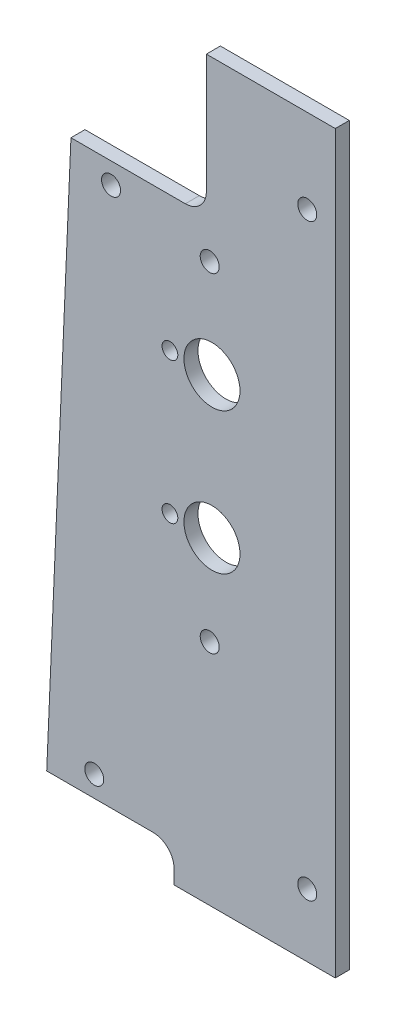
from build123d import *

# Parameters (mm, degrees)
BOSS_EXTRUDE1_DEPTH             = 3.175
F_9_64_0_14063_DIAMETER_HOLE1_D = 3.572002
F_1_2_0_5_DIAMETER_HOLE1_D      = 12.7
F_6_CLEARANCE_HOLE1_D           = 4.3053
F_6_CLEARANCE_HOLE2_D           = 4.3053
SKETCH13_W                      = 23.574867554
SKETCH13_H                      = 15.925568069
BOSS_EXTRUDE2_DEPTH             = 3.175


with BuildPart() as part:
    # Sketch1 → Boss-Extrude1 (new body)
    with BuildSketch(Plane.XY):
        with BuildLine():
            Line((-36.5125, 0), (0, 0))
            Line((0, 0), (0, 166.6875))
            Line((0, 166.6875), (-29.21, 166.6875))
            Line((-29.21, 166.6875), (-29.21, 139.7))
            ThreePointArc((-29.21, 139.7), (-30.604903955, 136.332403955), (-33.9725, 134.9375))
            Line((-33.9725, 134.9375), (-59.89066, 134.9375))
            Line((-59.89066, 134.9375), (-65.379450588, 7.9375))
            Line((-65.379450588, 7.9375), (-41.275, 7.9375))
            ThreePointArc((-41.275, 7.9375), (-37.907403955, 6.542596045), (-36.5125, 3.175))
            Line((-36.5125, 3.175), (-36.5125, 0))
        make_face()
    extrude(amount=-BOSS_EXTRUDE1_DEPTH)

    # 9/64 (0.14063) Diameter Hole1 (through all)
    with Locations(Plane.XY):
        with Locations((-18.415, 26.3525), (-37.465, 72.39), (-37.465, 104.394)):
            Hole(F_9_64_0_14063_DIAMETER_HOLE1_D / 2)

    # 1/2 (0.5) Diameter Hole1 (through all)
    with Locations(Plane.XY):
        with Locations((-27.94, 26.3525), (-27.94, 72.39), (-27.94, 104.394)):
            Hole(F_1_2_0_5_DIAMETER_HOLE1_D / 2)

    # #6 Clearance Hole1 (through all)
    with Locations(Plane.XY):
        with Locations((-28.448, 51.7525), (-28.448, 126.365)):
            Hole(F_6_CLEARANCE_HOLE1_D / 2)

    # #6 Clearance Hole2 (through all)
    with Locations(Plane.XY):
        with Locations((-50.8, 130.175), (-6.35, 147.6375), (-6.35, 14.2875), (-54.61, 12.7)):
            Hole(F_6_CLEARANCE_HOLE2_D / 2)

    # Sketch13 → Boss-Extrude2 (add, through all)
    with BuildSketch(Plane.XY):
        with Locations((-24.941412977, 26.424397309)):
            Rectangle(SKETCH13_W, SKETCH13_H)
    extrude(amount=-BOSS_EXTRUDE2_DEPTH)


solid = part.part
